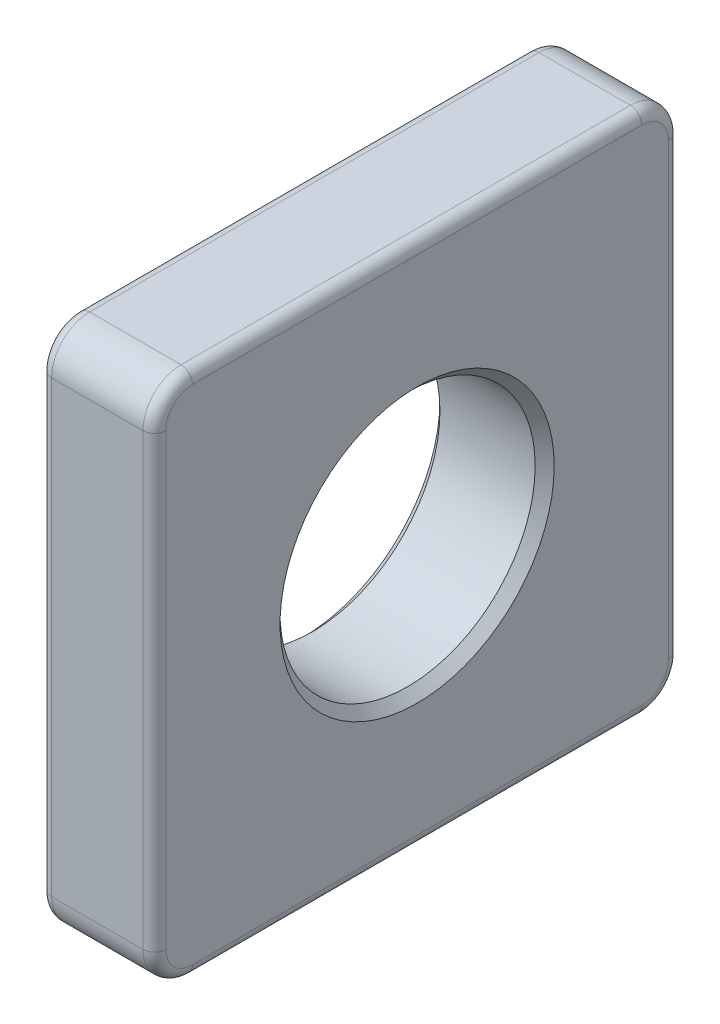
from build123d import *

# Parameters (mm, degrees)
SKETCH1_W           = 13.8
SKETCH1_H           = 13.8
BOSS_EXTRUDE1_DEPTH = 3
SKETCH2_R           = 3.35
CUT_EXTRUDE1_DEPTH  = 4
CHAMFER1_SIZE       = 0.25
FILLET1_R           = 1
FILLET2_R           = 0.3


with BuildPart() as part:
    # Sketch1 → Boss-Extrude1 (new body)
    with BuildSketch(Plane(origin=(0, 0, 0), x_dir=(0, 0, -1), z_dir=(1, 0, 0))):
        Rectangle(SKETCH1_W, SKETCH1_H)
    extrude(amount=BOSS_EXTRUDE1_DEPTH)

    # Sketch2 → Cut-Extrude1 (cut, through all)
    with BuildSketch(Plane(origin=(0, 0, 0), x_dir=(0, 0, -1), z_dir=(1, 0, 0))):
        Circle(SKETCH2_R)
    extrude(amount=CUT_EXTRUDE1_DEPTH, mode=Mode.SUBTRACT)

    # Chamfer1
    chamfer1_edges = [part.edges().sort_by_distance(p)[0] for p in [
        (0, 0, 3.35),
        (3, 0, 3.35),
    ]]
    chamfer(chamfer1_edges, length=CHAMFER1_SIZE)

    # Fillet1
    fillet1_edges = [part.edges().sort_by_distance(p)[0] for p in [
        (1.5, 6.9, 6.9),
        (1.5, 6.9, -6.9),
        (1.5, -6.9, -6.9),
        (1.5, -6.9, 6.9),
    ]]
    fillet(fillet1_edges, radius=FILLET1_R)

    # Fillet2
    fillet2_edges = [part.edges().sort_by_distance(p)[0] for p in [
        (0, 6.9, 0),
        (3, 6.9, 0),
        (0, 0, 6.9),
        (0, 0, -6.9),
        (0, -6.9, 0),
        (0, 6.607106781, 6.607106781),
        (0, -6.607106781, 6.607106781),
        (0, -6.607106781, -6.607106781),
        (0, 6.607106781, -6.607106781),
        (3, 0, -6.9),
        (3, 0, 6.9),
        (3, -6.9, 0),
        (3, 6.607106781, 6.607106781),
        (3, -6.607106781, 6.607106781),
        (3, -6.607106781, -6.607106781),
        (3, 6.607106781, -6.607106781),
    ]]
    fillet(fillet2_edges, radius=FILLET2_R)


solid = part.part
